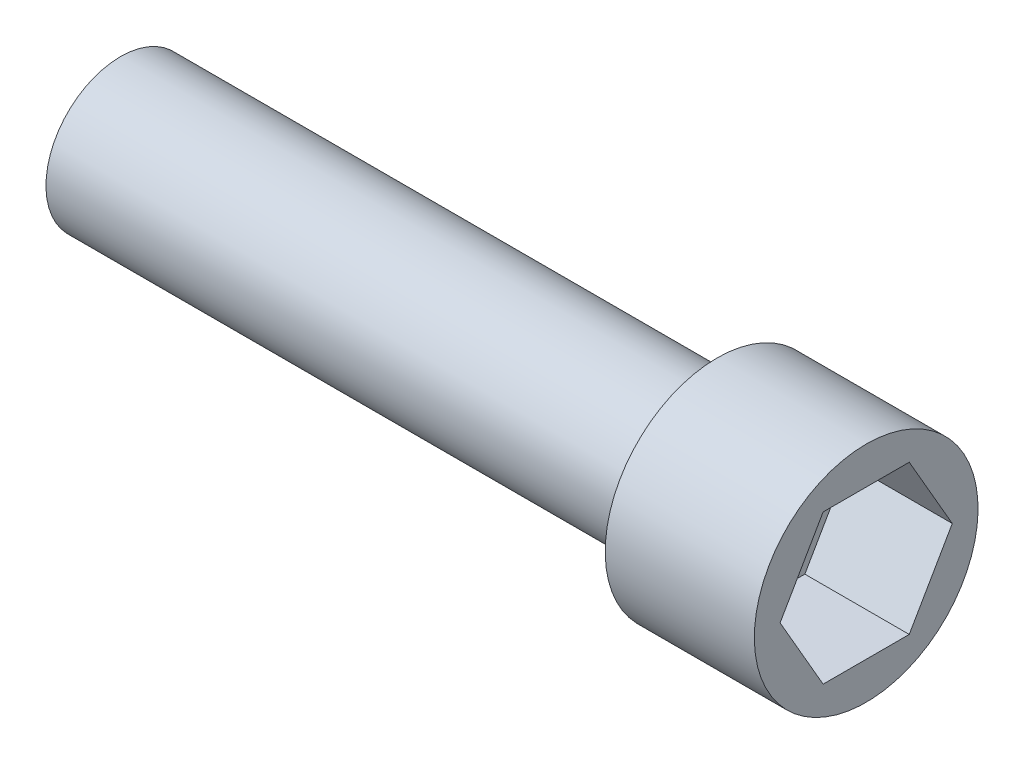
from build123d import *

# Parameters (mm, degrees)
CUT_EXTRUDE1_DEPTH = 7


with BuildPart() as part:
    # Sketch1 → Revolve1 (revolve)
    with BuildSketch(Plane.XY):
        Polygon((-25, 5), (15, 5), (15, 7.5), (25, 7.5), (25, 0), (-25, 0), align=None)
    revolve(axis=Axis((25, 0, 0), (-1, 0, 0)))

    # Sketch2 → Cut-Extrude1 (cut)
    with BuildSketch(Plane(origin=(25, 0, 0), x_dir=(0, 0, -1), z_dir=(1, 0, 0))):
        Polygon((5.773502692, 0), (2.886751346, 5), (-2.886751346, 5), (-5.773502692, 0), (-2.886751346, -5), (2.886751346, -5), align=None)
    extrude(amount=-CUT_EXTRUDE1_DEPTH, mode=Mode.SUBTRACT)


solid = part.part
